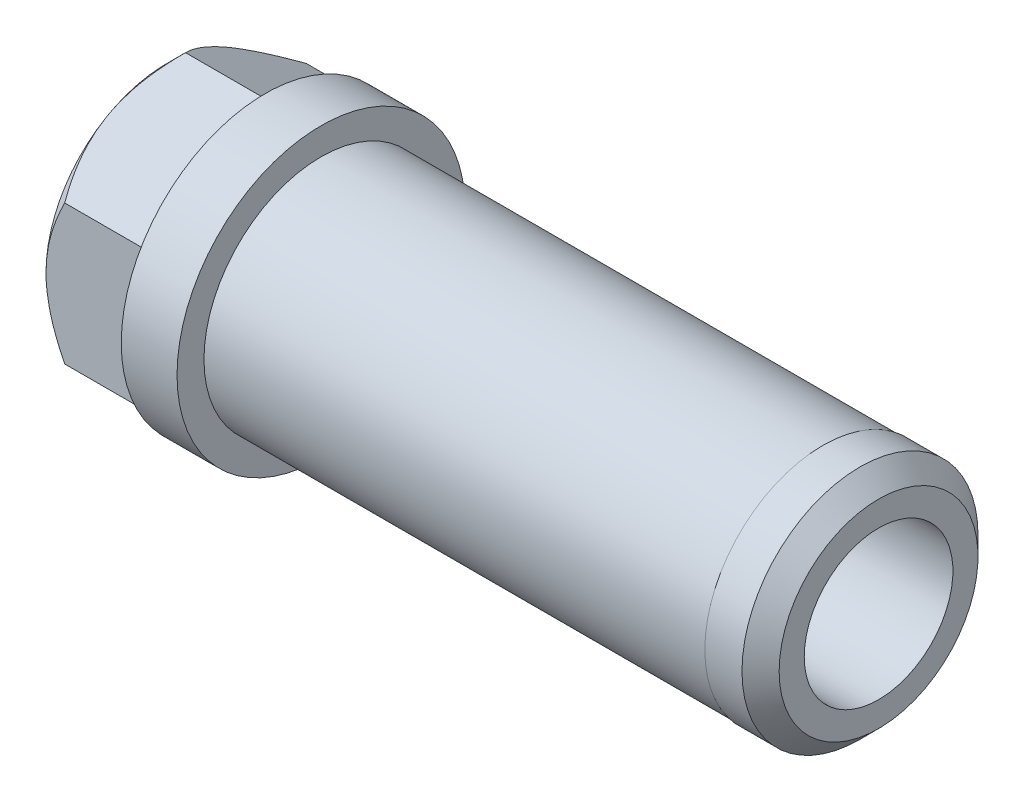
from build123d import *

# Parameters (mm, degrees)
SFAZOWANIE2_SIZE            = 1
SZKIC2_W                    = 27
SZKIC2_H                    = 0.05
SZKIC3_R                    = 4
DODANIE_WYCI_GNI_CIE1_DEPTH = 5.3
SFAZOWANIE3_SIZE            = 0.5


with BuildPart() as part:
    # Szkic1 → Obrót1 (revolve)
    with BuildSketch(Plane.XY, mode=Mode.PRIVATE) as obr_t1_sk:
        Polygon((0, 4), (33, 4), (33, 6.35), (3, 6.35), (3, 7.75), (0, 7.75), align=None)
    revolve(obr_t1_sk.sketch.rotate(Axis((0, 0, 0), (1, 0, 0)), 90), axis=Axis((0, 0, 0), (1, 0, 0)))

    # Sfazowanie2
    sfazowanie2_edges = [part.edges().sort_by_distance(p)[0] for p in [
        (33, 0, -6.35),
    ]]
    chamfer(sfazowanie2_edges, length=SFAZOWANIE2_SIZE)

    # Szkic2 → Wycięcie-obrót1 (revolve, cut)
    with BuildSketch(Plane.XY, mode=Mode.PRIVATE) as wyci_cie_obr_t1_sk:
        with Locations((16.5, 6.325)):
            Rectangle(SZKIC2_W, SZKIC2_H)
    revolve(wyci_cie_obr_t1_sk.sketch.rotate(Axis((3, 0, 0), (1, 0, 0)), 90), axis=Axis((3, 0, 0), (1, 0, 0)), mode=Mode.SUBTRACT)

    # Szkic3 → Dodanie-wyciągnięcie1 (add)
    with BuildSketch(Plane.ZY):
        Polygon((6.5, -3.75277675), (6.5, 3.75277675), (0, 7.505553499), (-6.5, 3.75277675), (-6.5, -3.75277675), (0, -7.505553499), align=None)
        Circle(SZKIC3_R, mode=Mode.SUBTRACT)
    extrude(amount=DODANIE_WYCI_GNI_CIE1_DEPTH)

    # Szkic4 → Wycięcie-obrót2 (revolve, cut)
    with BuildSketch(Plane(origin=(0, 0, 0), x_dir=(1, 0, 0), z_dir=(0, 1, 0)), mode=Mode.PRIVATE) as wyci_cie_obr_t2_sk:
        Polygon((-5.3, 6.5), (-5.3, 10), (-1.8, 10), align=None)
    revolve(wyci_cie_obr_t2_sk.sketch.rotate(Axis((0, 0, 0), (-1, 0, 0)), 180), axis=Axis((0, 0, 0), (-1, 0, 0)), mode=Mode.SUBTRACT)

    # Sfazowanie3
    sfazowanie3_edges = [part.edges().sort_by_distance(p)[0] for p in [
        (-5.3, 0, -4),
    ]]
    chamfer(sfazowanie3_edges, length=SFAZOWANIE3_SIZE)


solid = part.part
